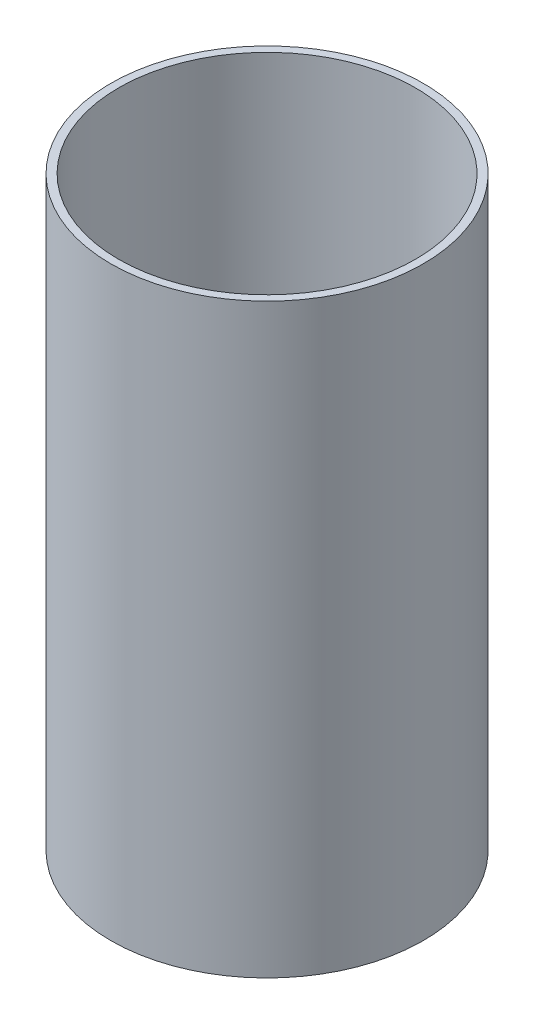
from build123d import *

# Parameters (mm, degrees)
SKETCH_1_R      = 40
SKETCH_1_R_2    = 38
EXTRUDE_1_DEPTH = 150


with BuildPart() as part:
    # 草图1 → 凸台-拉伸1 (new body)
    with BuildSketch(Plane(origin=(0, 0, 0), x_dir=(1, 0, 0), z_dir=(0, 1, 0))):
        Circle(SKETCH_1_R)
        Circle(SKETCH_1_R_2, mode=Mode.SUBTRACT)
    extrude(amount=EXTRUDE_1_DEPTH)


solid = part.part
